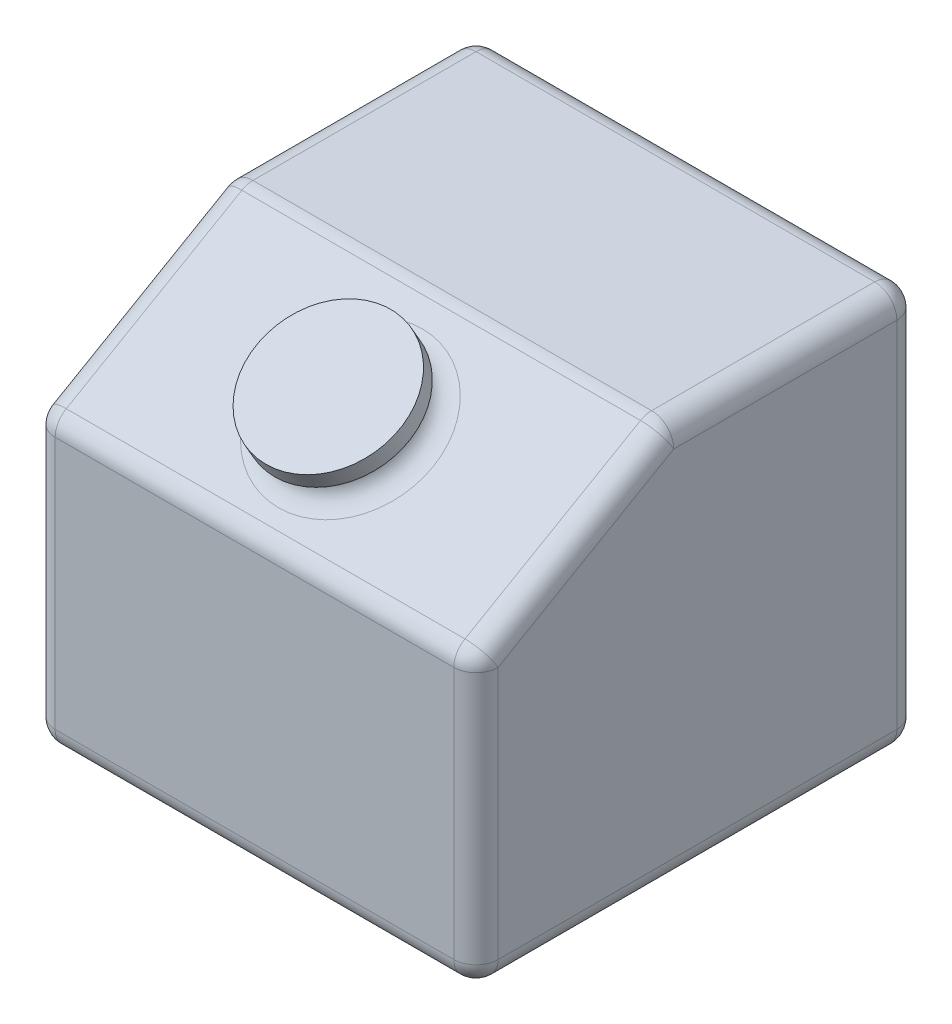
from build123d import *

# Parameters (mm, degrees)
SKETCH_1_W          = 200
SKETCH_1_H          = 200
EXTRUDE_1_DEPTH     = 180
CHAMFER_1_SIZE      = 50
CHAMFER_1_SIZE2     = 86.602540378
SKETCH_2_R          = 27.5
EXTRUDE_2_DEPTH     = 20
EXTRUDE_START       = 12
SKETCH_2_3_R        = 32.5
SKETCH_2_3_R_2      = 27.5
EXTRUDE_3_DEPTH     = 8
FILLET_1_R          = 10
CUT_EXTRUDE_START   = -10
CUT_EXTRUDE_1_DEPTH = 180


with BuildPart() as part:
    # 스케치1 → 보스-돌출1 (new body)
    with BuildSketch(Plane(origin=(0, 0, 0), x_dir=(1, 0, 0), z_dir=(0, 1, 0))):
        with Locations((100, 100)):
            Rectangle(SKETCH_1_W, SKETCH_1_H)
    extrude(amount=EXTRUDE_1_DEPTH)

    # 모따기1
    chamfer_1_edges = [part.edges().sort_by_distance(p)[0] for p in [
        (100, 180, 0),
    ]]
    chamfer_1_side = [part.faces().sort_by_distance(p)[0] for p in [
        (100, 90, 0),
    ]]
    chamfer(chamfer_1_edges, length=CHAMFER_1_SIZE, length2=CHAMFER_1_SIZE2, reference=chamfer_1_side[0])

    # 스케치2 → 보스-돌출2 (add)
    with BuildSketch(Plane(origin=(0, 97.5, 56.291651246), x_dir=(1, 0, 0), z_dir=(0, 0.8660254037844379, 0.5000000000000014))):
        with Locations((100, 115)):
            Circle(SKETCH_2_R)
    extrude(amount=EXTRUDE_2_DEPTH)

    # 스케치2<3> → 보스-돌출3 (add)
    with BuildSketch(Plane(origin=(0, 97.5, 56.291651246), x_dir=(1, 0, 0), z_dir=(0, 0.8660254037844379, 0.5000000000000014)).offset(EXTRUDE_START)):
        with Locations((100, 115)):
            Circle(SKETCH_2_3_R)
        with Locations((100, 115)):
            Circle(SKETCH_2_3_R_2, mode=Mode.SUBTRACT)
    extrude(amount=EXTRUDE_3_DEPTH)

    # 필렛1
    fillet_1_edges = [part.edges().sort_by_distance(p)[0] for p in [
        (72.5, 155, -43.301270189),
        (100, 180, -86.602540378),
        (0, 180, -143.301270189),
        (0, 155, -43.301270189),
        (100, 180, -200),
        (0, 90, -200),
        (200, 90, -200),
        (200, 155, -43.301270189),
        (200, 180, -143.301270189),
        (0, 65, 0),
        (100, 130, 0),
        (200, 65, 0),
        (100, 0, 0),
        (200, 0, -100),
        (100, 0, -200),
        (0, 0, -100),
    ]]
    fillet(fillet_1_edges, radius=FILLET_1_R)

    # 스케치3 → 컷-돌출1 (cut)
    with BuildSketch(Plane(origin=(200, 0, 0), x_dir=(0, 0, -1), z_dir=(1, 0, 0)).offset(CUT_EXTRUDE_START)):
        Polygon((187, 13), (187, 167), (90.08587988, 167), (13, 122.494446501), (13, 13), align=None)
    extrude(amount=-CUT_EXTRUDE_1_DEPTH, mode=Mode.SUBTRACT)


solid = part.part
